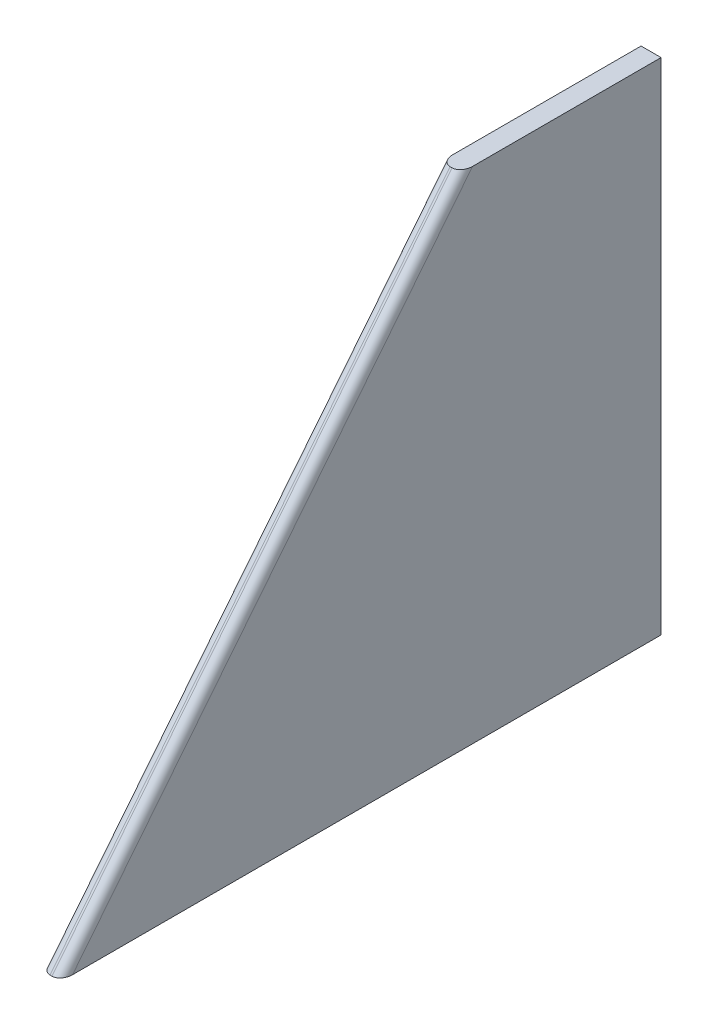
from build123d import *

# Parameters (mm, degrees)
BOSS_EXTRUDE1_DEPTH = 1.27
FILLET1_R           = 1.143


with BuildPart() as part:
    # Sketch1 → Boss-Extrude1 (new body, symmetric)
    with BuildSketch(Plane(origin=(0, 0, 0), x_dir=(0, 0, -1), z_dir=(1, 0, 0))):
        Polygon((0, 0), (76.2, 0), (76.2, 63.5), (50.8, 63.5), align=None)
    extrude(amount=BOSS_EXTRUDE1_DEPTH, both=True)

    # Fillet1
    fillet1_edges = [part.edges().sort_by_distance(p)[0] for p in [
        (1.27, 31.75, -25.4),
        (-1.27, 31.75, -25.4),
    ]]
    fillet(fillet1_edges, radius=FILLET1_R)


solid = part.part
